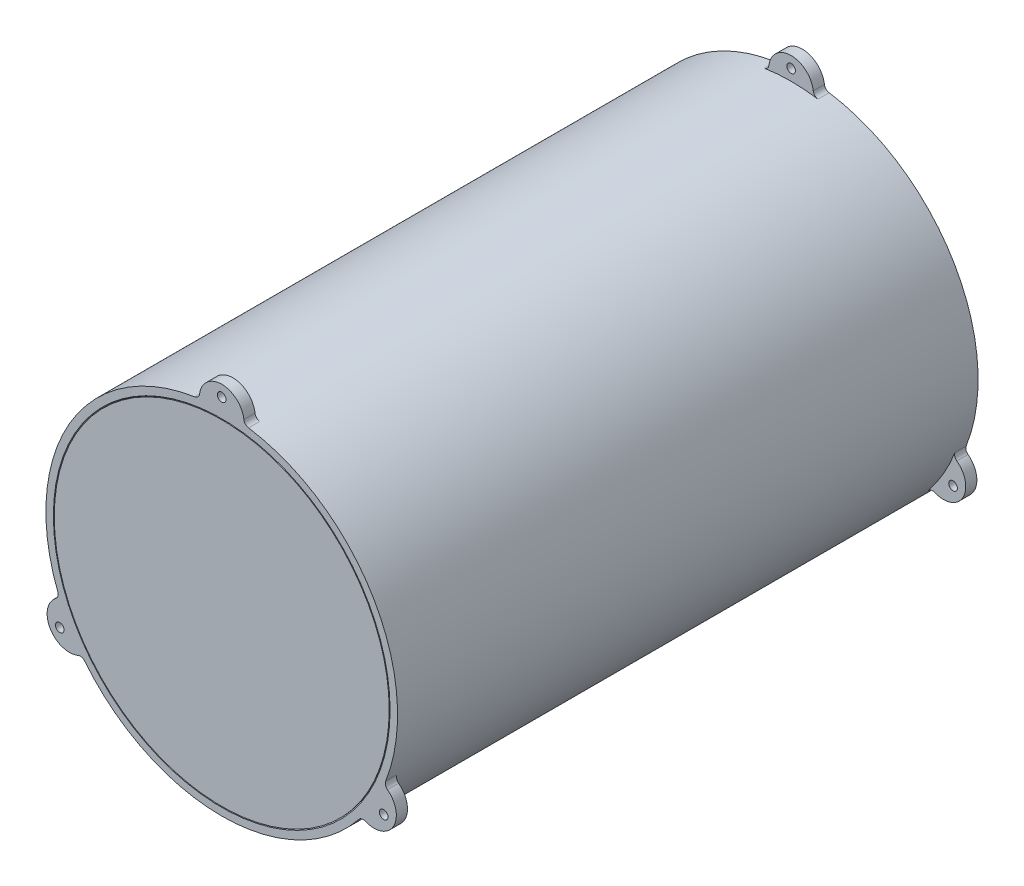
from build123d import *

# Parameters (mm, degrees)
SKETCH1_R                    = 100.0125
SKETCH1_R_2                  = 95.25
EXTRUDE1_DEPTH               = 330.2
EXTRUDE2_DEPTH               = 6.35
EXTRUDE4_DEPTH               = 6.35
F_10_0_1935_DIAMETER_HOLE1_D = 4.9149
CHAMFER1_SIZE                = 0.508
FILLET1_R                    = 3.175
SKETCH1_3_R                  = 95.25
BOSS_EXTRUDE1_DEPTH          = 330.2


with BuildPart() as part:
    # Sketch1 → Extrude1 (new body)
    with BuildSketch(Plane.XY):
        Circle(SKETCH1_R)
        Circle(SKETCH1_R_2, mode=Mode.SUBTRACT)
    extrude(amount=EXTRUDE1_DEPTH)

    # Sketch2 → Extrude2 (add)
    with BuildSketch(Plane.XY):
        with BuildLine():
            ThreePointArc((-12.674375762, 99.206150794), (0, 100.0125), (12.674375762, 99.206150794))
            ThreePointArc((12.674375762, 99.206150794), (0, 112.7125), (-12.674375762, 99.206150794))
        make_face()
        with BuildLine():
            ThreePointArc((-79.577858918, -60.579406784), (-86.613365696, -50.00625), (-92.25223468, -38.62674401))
            ThreePointArc((-92.25223468, -38.62674401), (-97.611888324, -56.35625), (-79.577858918, -60.579406784))
        make_face()
        with BuildLine():
            ThreePointArc((79.577858918, -60.579406784), (97.611888324, -56.35625), (92.25223468, -38.62674401))
            ThreePointArc((92.25223468, -38.62674401), (86.613365696, -50.00625), (79.577858918, -60.579406784))
        make_face()
    extrude(amount=EXTRUDE2_DEPTH)

    # Sketch3 → Extrude4 (add)
    with BuildSketch(Plane.XY.offset(330.2)):
        with BuildLine():
            ThreePointArc((12.674375762, 99.206150794), (0, 112.7125), (-12.674375762, 99.206150794))
            ThreePointArc((-12.674375762, 99.206150794), (0, 100.0125), (12.674375762, 99.206150794))
        make_face()
        with BuildLine():
            ThreePointArc((92.25223468, -38.62674401), (86.613365696, -50.00625), (79.577858918, -60.579406784))
            ThreePointArc((79.577858918, -60.579406784), (97.611888324, -56.35625), (92.25223468, -38.62674401))
        make_face()
        with BuildLine():
            ThreePointArc((-92.25223468, -38.62674401), (-97.611888324, -56.35625), (-79.577858918, -60.579406784))
            ThreePointArc((-79.577858918, -60.579406784), (-86.613365696, -50.00625), (-92.25223468, -38.62674401))
        make_face()
    extrude(amount=-EXTRUDE4_DEPTH)

    # 10 _0.1935_ Diameter Hole1 (through all)
    with Locations(Plane(origin=(0, 106.3625, 0), x_dir=(-1, 0, 0), z_dir=(0, 0, -1))):
        with Locations((0, 0), (-92.11262701, -159.54375), (92.11262701, -159.54375)):
            Hole(F_10_0_1935_DIAMETER_HOLE1_D / 2)

    # Chamfer1
    chamfer1_edges = [part.edges().sort_by_distance(p)[0] for p in [
        (-95.25, 0, 0),
        (-95.25, 0, 330.2),
    ]]
    chamfer(chamfer1_edges, length=CHAMFER1_SIZE)

    # Fillet1
    fillet1_edges = [part.edges().sort_by_distance(p)[0] for p in [
        (79.577858918, -60.579406784, 3.175),
        (92.25223468, -38.62674401, 3.175),
        (-12.674375762, 99.206150794, 3.175),
        (12.674375762, 99.206150794, 3.175),
        (-92.25223468, -38.62674401, 3.175),
        (-79.577858918, -60.579406784, 3.175),
        (-79.577858918, -60.579406784, 327.025),
        (-92.25223468, -38.62674401, 327.025),
        (-12.674375762, 99.206150794, 327.025),
        (12.674375762, 99.206150794, 327.025),
        (92.25223468, -38.62674401, 327.025),
        (79.577858918, -60.579406784, 327.025),
    ]]
    fillet(fillet1_edges, radius=FILLET1_R)


with BuildPart() as body_2:
    # Sketch1_3 → Boss-Extrude1 (new body)
    with BuildSketch(Plane.XY):
        Circle(SKETCH1_3_R)
    extrude(amount=BOSS_EXTRUDE1_DEPTH)


solid = Compound([part.part, body_2.part])
